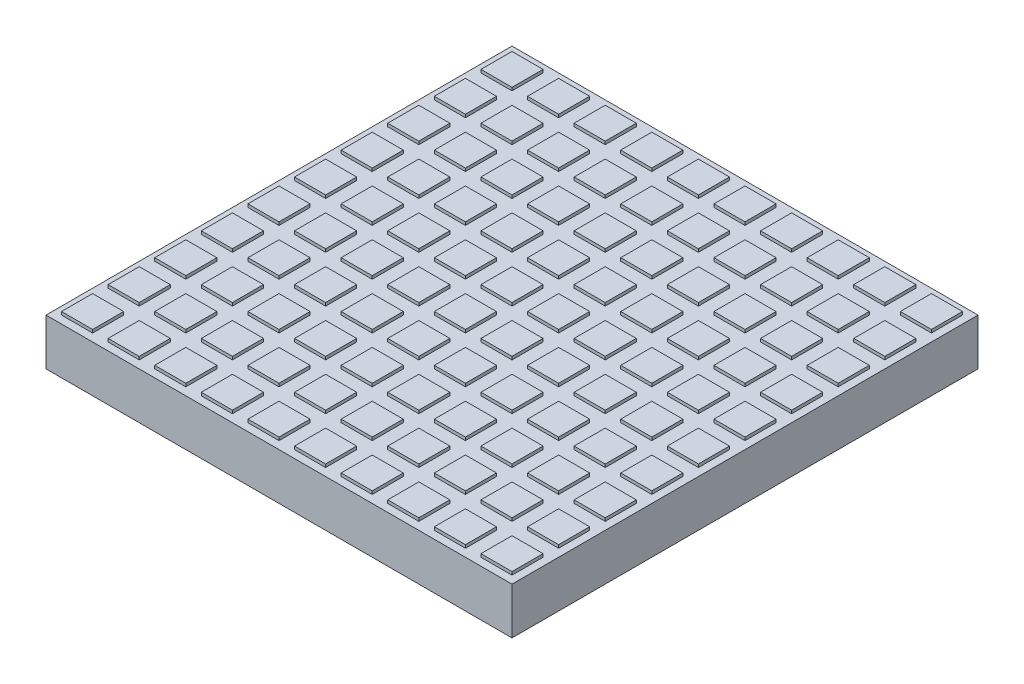
from build123d import *

# Parameters (mm, degrees)
SKETCH1_W            = 300
SKETCH1_H            = 300
BOSS_EXTRUDE1_DEPTH  = 30
SKETCH2_W            = 20
SKETCH2_H            = 20
BOSS_EXTRUDE2_DEPTH  = 2
LPATTERN1_COUNT      = 10
LPATTERN1_PITCH      = 30
LPATTERN1_COUNT_DIR2 = 10
LPATTERN1_PITCH_DIR2 = 30


with BuildPart() as part:
    # Sketch1 → Boss-Extrude1 (new body)
    with BuildSketch(Plane(origin=(0, 0, 0), x_dir=(1, 0, 0), z_dir=(0, 1, 0))):
        with Locations((150, 150)):
            Rectangle(SKETCH1_W, SKETCH1_H)
    extrude(amount=BOSS_EXTRUDE1_DEPTH)

    # Sketch2 → Boss-Extrude2 (add)
    with BuildSketch(Plane(origin=(0, 30, 0), x_dir=(1, 0, 0), z_dir=(0, 1, 0))):
        with Locations((15, 285)):
            Rectangle(SKETCH2_W, SKETCH2_H)
    boss_extrude2 = extrude(amount=BOSS_EXTRUDE2_DEPTH)

    # LPattern1: Boss-Extrude2 10 × 10
    with Locations(*[(i * LPATTERN1_PITCH, 0, j * LPATTERN1_PITCH_DIR2) for i in range(LPATTERN1_COUNT) for j in range(LPATTERN1_COUNT_DIR2) if (i, j) != (0, 0)]):
        add(boss_extrude2)


solid = part.part
